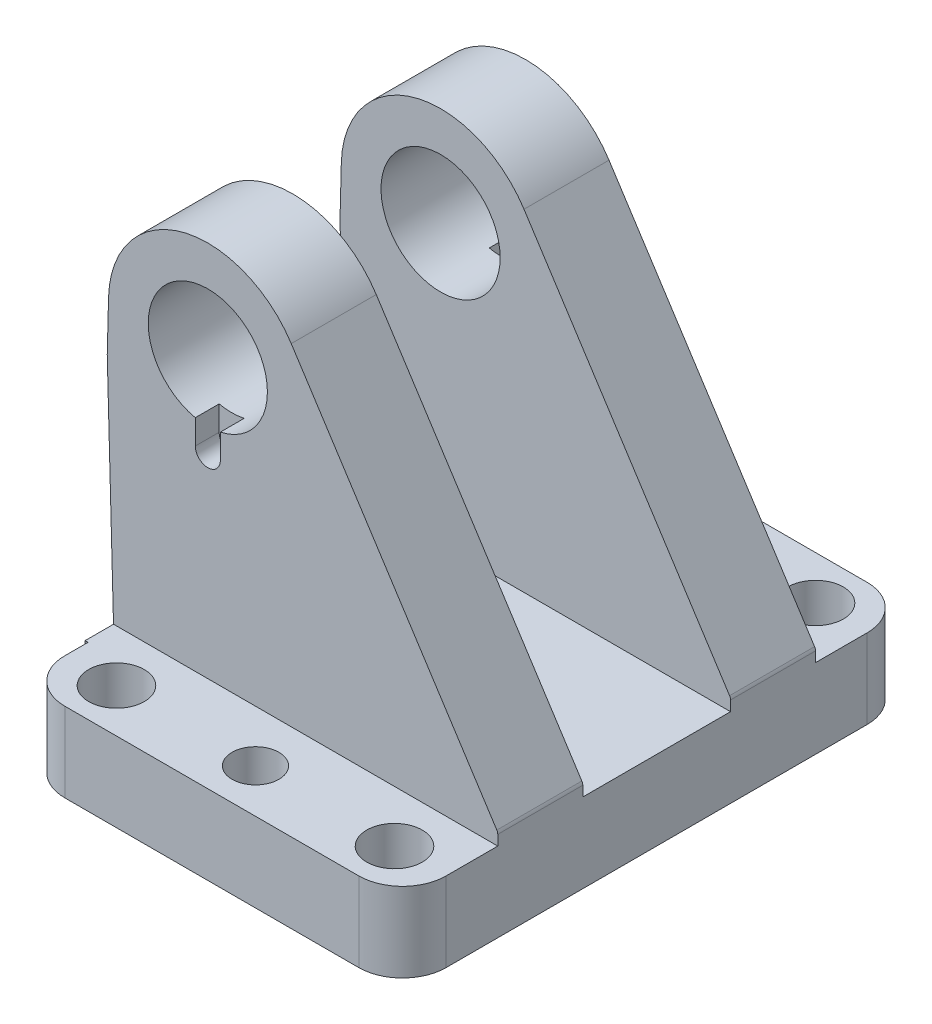
from build123d import *

# Parameters (mm, degrees)
SKETCH1_R                = 7
SKETCH1_R_2              = 5.9
BOSS_EXTRUDE1_DEPTH      = 20
BOSS_EXTRUDE2_DEPTH      = 47.15
BOSS_EXTRUDE2_DEPTH_BACK = 47.15
SKETCH3_R                = 15
BOSS_EXTRUDE3_DEPTH      = 21.4
SKETCH4_R                = 15
BOSS_EXTRUDE4_DEPTH      = 21.4
CUT_EXTRUDE1_DEPTH       = 6
CUT_EXTRUDE1_DEPTH_BACK  = 6
CUT_EXTRUDE2_DEPTH       = 6
CUT_EXTRUDE2_DEPTH_BACK  = 6


with BuildPart() as part:
    # Sketch1 → Boss-Extrude1 (new body)
    with BuildSketch(Plane(origin=(0, 0, 0), x_dir=(1, 0, 0), z_dir=(0, 1, 0))):
        with BuildLine():
            Line((-37, -64), (37, -64))
            ThreePointArc((37, -64), (44.778174593, -60.778174593), (48, -53))
            Line((48, -53), (48, 53))
            ThreePointArc((48, 53), (44.778174593, 60.778174593), (37, 64))
            Line((37, 64), (-37, 64))
            ThreePointArc((-37, 64), (-44.778174593, 60.778174593), (-48, 53))
            Line((-48, 53), (-48, -53))
            ThreePointArc((-48, -53), (-44.778174593, -60.778174593), (-37, -64))
        make_face()
        with Locations((35, 53)):
            Circle(SKETCH1_R, mode=Mode.SUBTRACT)
        with Locations((35, -53)):
            Circle(SKETCH1_R, mode=Mode.SUBTRACT)
        with Locations((0, 53)):
            Circle(SKETCH1_R_2, mode=Mode.SUBTRACT)
        with Locations((0, -53)):
            Circle(SKETCH1_R_2, mode=Mode.SUBTRACT)
        with Locations((-35, 53)):
            Circle(SKETCH1_R, mode=Mode.SUBTRACT)
        with Locations((-35, -53)):
            Circle(SKETCH1_R, mode=Mode.SUBTRACT)
    extrude(amount=BOSS_EXTRUDE1_DEPTH)

    # Sketch2 → Boss-Extrude2 (add, two sides)
    with BuildSketch(Plane.XY) as boss_extrude2_sk:
        Polygon((-48.744328002, 20), (-48.2, 0), (-43.2, 0), (-43.2, 20), align=None)
    extrude(amount=BOSS_EXTRUDE2_DEPTH)
    extrude(boss_extrude2_sk.sketch, amount=-BOSS_EXTRUDE2_DEPTH_BACK)

    # Sketch3 → Boss-Extrude3 (add)
    with BuildSketch(Plane.XY.offset(40)):
        with BuildLine():
            Line((-50.322839283, 77.998533118), (-48.2, 0))
            Line((-48.2, 0), (48, 0))
            Line((48, 0), (48, 22.55795714))
            ThreePointArc((48, 22.55795714), (47.938823082, 22.981971454), (47.760282483, 23.371399248))
            Line((47.760282483, 23.371399248), (-3.995291952, 103.55736847))
            ThreePointArc((-3.995291952, 103.55736847), (-31.752406245, 114.070833178), (-49.991433124, 90.654423708))
            Line((-49.991433124, 90.654423708), (-50.322839283, 77.998533118))
        make_face()
        with Locations((-25, 90)):
            Circle(SKETCH3_R, mode=Mode.SUBTRACT)
    extrude(amount=-BOSS_EXTRUDE3_DEPTH)

    # Sketch4 → Boss-Extrude4 (add)
    with BuildSketch(Plane.XY.offset(-40)):
        with BuildLine():
            Line((-50.322839283, 77.998533118), (-48.2, 0))
            Line((-48.2, 0), (48, 0))
            Line((48, 0), (48, 22.55795714))
            ThreePointArc((48, 22.55795714), (47.938823082, 22.981971454), (47.760282483, 23.371399248))
            Line((47.760282483, 23.371399248), (-3.995291952, 103.55736847))
            ThreePointArc((-3.995291952, 103.55736847), (-31.752406245, 114.070833178), (-49.991433124, 90.654423708))
            Line((-49.991433124, 90.654423708), (-50.322839283, 77.998533118))
        make_face()
        with Locations((-25, 90)):
            Circle(SKETCH4_R, mode=Mode.SUBTRACT)
    extrude(amount=BOSS_EXTRUDE4_DEPTH)

    # Sketch5 → Cut-Extrude1 (cut, two sides)
    with BuildSketch(Plane.XY.offset(40)) as cut_extrude1_sk:
        with BuildLine():
            Line((-21.85, 69.15), (-21.85, 90))
            Line((-21.85, 90), (-28.15, 90))
            Line((-28.15, 90), (-28.15, 69.15))
            ThreePointArc((-28.15, 69.15), (-25, 66), (-21.85, 69.15))
        make_face()
    extrude(amount=CUT_EXTRUDE1_DEPTH, mode=Mode.SUBTRACT)
    extrude(cut_extrude1_sk.sketch, amount=-CUT_EXTRUDE1_DEPTH_BACK, mode=Mode.SUBTRACT)

    # Sketch6 → Cut-Extrude2 (cut, two sides)
    with BuildSketch(Plane.XY.offset(-40)) as cut_extrude2_sk:
        with BuildLine():
            Line((-21.85, 69.15), (-21.85, 90))
            Line((-21.85, 90), (-28.15, 90))
            Line((-28.15, 90), (-28.15, 69.15))
            ThreePointArc((-28.15, 69.15), (-25, 66), (-21.85, 69.15))
        make_face()
    extrude(amount=CUT_EXTRUDE2_DEPTH, mode=Mode.SUBTRACT)
    extrude(cut_extrude2_sk.sketch, amount=-CUT_EXTRUDE2_DEPTH_BACK, mode=Mode.SUBTRACT)


solid = part.part
